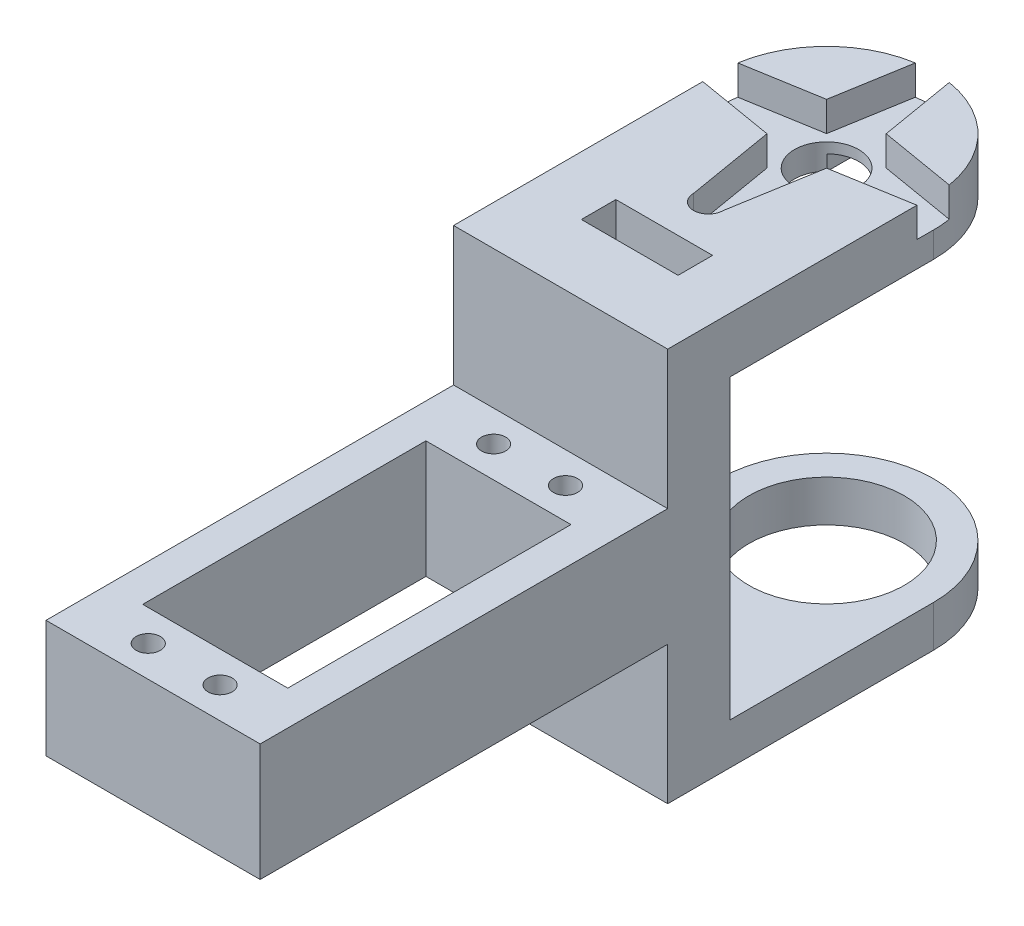
from build123d import *

# Parameters (mm, degrees)
BOSS_EXTRUDE1_DEPTH = 9
SKETCH4_W           = 31
SKETCH4_H           = 8
SKETCH4_H_2         = 6
BOSS_EXTRUDE4_DEPTH = 45
CUT_EXTRUDE1_DEPTH  = 58
SKETCH6_3_R         = 11.25
CUT_EXTRUDE2_DEPTH  = 6
CUT_EXTRUDE3_DEPTH  = 4.3
CUT_EXTRUDE4_DEPTH  = 2.2
SKETCH9_3_R         = 4.65
CUT_EXTRUDE5_DEPTH  = 8
SKETCH10_W          = 31
SKETCH10_H          = 17
BOSS_EXTRUDE5_DEPTH = 59
SKETCH11_R          = 1.75
SKETCH11_W          = 21
SKETCH11_H          = 41
CUT_EXTRUDE6_DEPTH  = 38
SKETCH13_W          = 14
SKETCH13_H          = 5
CUT_EXTRUDE8_DEPTH  = 9


with BuildPart() as part:
    # Sketch1 → Boss-Extrude1 (new body)
    with BuildSketch(Plane.XY):
        Polygon((15.5, -28.5), (-15.5, -28.5), (-15.5, -10.3), (-15.5, 10.3), (-15.5, 28.5), (15.5, 28.5), align=None)
    extrude(amount=BOSS_EXTRUDE1_DEPTH)

    # Sketch4 → Boss-Extrude4 (add)
    with BuildSketch(Plane(origin=(0, 0, 0), x_dir=(-1, 0, 0), z_dir=(0, 0, -1))):
        with Locations((0, 24.5)):
            Rectangle(SKETCH4_W, SKETCH4_H)
        with Locations((0, -25.5)):
            Rectangle(SKETCH4_W, SKETCH4_H_2)
    extrude(amount=BOSS_EXTRUDE4_DEPTH)

    # Sketch6 → Cut-Extrude1 (cut, through all)
    with BuildSketch(Plane.XZ.offset(28.5)):
        with BuildLine():
            ThreePointArc((15.5, -29.5), (10.960155101, -40.460155116), (-2.1e-08, -45))
            Line((-2.1e-08, -45), (15.5, -45))
            Line((15.5, -45), (15.5, -29.5))
        make_face()
        with BuildLine():
            ThreePointArc((-2.1e-08, -45), (-10.960155116, -40.460155101), (-15.5, -29.5))
            Line((-15.5, -29.5), (-15.5, -45))
            Line((-15.5, -45), (-2.1e-08, -45))
        make_face()
    extrude(amount=-CUT_EXTRUDE1_DEPTH, mode=Mode.SUBTRACT)

    # Sketch6_3 → Cut-Extrude2 (cut)
    with BuildSketch(Plane.XZ.offset(28.5)):
        with Locations((0, -29.5)):
            Circle(SKETCH6_3_R)
    extrude(amount=-CUT_EXTRUDE2_DEPTH, mode=Mode.SUBTRACT)

    # Sketch7 → Cut-Extrude3 (cut)
    with BuildSketch(Plane(origin=(0, 28.5, 0), x_dir=(1, 0, 0), z_dir=(0, 1, 0))):
        with BuildLine():
            Line((-17.1, 31.65), (-4.313351365, 33.813351365))
            Line((-4.313351365, 33.813351365), (-2.15, 46.6))
            ThreePointArc((-2.15, 46.6), (0, 48.75), (2.15, 46.6))
            Line((2.15, 46.6), (4.313351365, 33.813351365))
            Line((4.313351365, 33.813351365), (17.1, 31.65))
            ThreePointArc((17.1, 31.65), (19.25, 29.5), (17.1, 27.35))
            Line((17.1, 27.35), (4.313351365, 25.186648635))
            Line((4.313351365, 25.186648635), (2.15, 12.4))
            ThreePointArc((2.15, 12.4), (0, 10.25), (-2.15, 12.4))
            Line((-2.15, 12.4), (-4.313351365, 25.186648635))
            Line((-4.313351365, 25.186648635), (-17.1, 27.35))
            ThreePointArc((-17.1, 27.35), (-19.25, 29.5), (-17.1, 31.65))
        make_face()
    extrude(amount=-CUT_EXTRUDE3_DEPTH, mode=Mode.SUBTRACT)

    # Sketch9 → Cut-Extrude4 (cut)
    with BuildSketch(Plane.XZ.offset(-20.5)):
        with BuildLine():
            ThreePointArc((3.25, -32.82565783), (0, -34.15), (-3.25, -32.82565783))
            Line((-3.25, -32.82565783), (-3.25, -44.655444566))
            ThreePointArc((-3.25, -44.655444566), (0, -45), (3.25, -44.655444566))
            Line((3.25, -44.655444566), (3.25, -32.82565783))
        make_face()
    extrude(amount=-CUT_EXTRUDE4_DEPTH, mode=Mode.SUBTRACT)

    # Sketch9_3 → Cut-Extrude5 (cut)
    with BuildSketch(Plane.XZ.offset(-20.5)):
        with Locations((0, -29.5)):
            Circle(SKETCH9_3_R)
    extrude(amount=-CUT_EXTRUDE5_DEPTH, mode=Mode.SUBTRACT)

    # Sketch10 → Boss-Extrude5 (add)
    with BuildSketch(Plane.XY.offset(9)):
        Rectangle(SKETCH10_W, SKETCH10_H)
    extrude(amount=BOSS_EXTRUDE5_DEPTH)

    # Sketch11 → Cut-Extrude6 (cut, through all)
    with BuildSketch(Plane.XZ.offset(8.5)):
        with Locations((5.2, 13.5)):
            Circle(SKETCH11_R)
        with Locations((-5.2, 13.5)):
            Circle(SKETCH11_R)
        with Locations((5.2, 63.5)):
            Circle(SKETCH11_R)
        with Locations((-5.2, 63.5)):
            Circle(SKETCH11_R)
        with Locations((0, 38.5)):
            Rectangle(SKETCH11_W, SKETCH11_H)
    extrude(amount=-CUT_EXTRUDE6_DEPTH, mode=Mode.SUBTRACT)

    # Sketch13 → Cut-Extrude8 (cut)
    with BuildSketch(Plane(origin=(0, 28.5, 0), x_dir=(1, 0, 0), z_dir=(0, 1, 0))):
        with Locations((0, 3.5)):
            Rectangle(SKETCH13_W, SKETCH13_H)
    extrude(amount=-CUT_EXTRUDE8_DEPTH, mode=Mode.SUBTRACT)


solid = part.part
